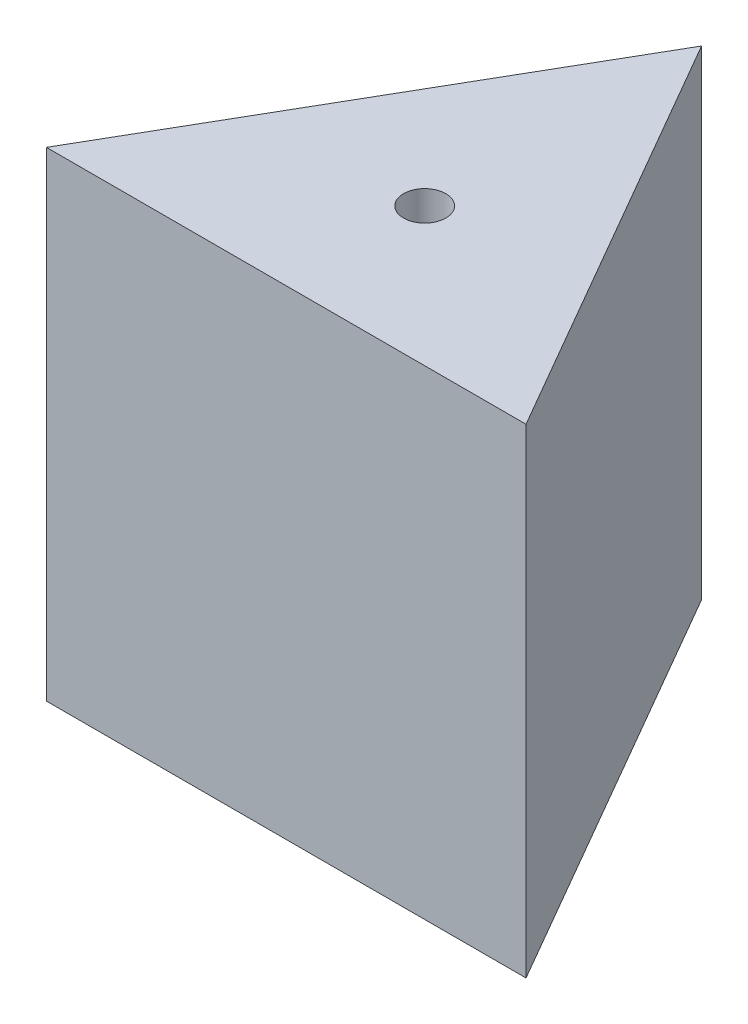
from build123d import *

# Parameters (mm, degrees)
BOSS_EXTRUDE1_DEPTH = 431.8
SKETCH2_R           = 19.05
CUT_EXTRUDE1_DEPTH  = 432.8


with BuildPart() as part:
    # Sketch1 → Boss-Extrude1 (new body)
    with BuildSketch(Plane(origin=(0, 0, 0), x_dir=(1, 0, 0), z_dir=(0, 1, 0))):
        Polygon((0, 0), (-215.9, -373.949769354), (215.9, -373.949769354), align=None)
    extrude(amount=BOSS_EXTRUDE1_DEPTH)

    # Sketch2 → Cut-Extrude1 (cut, through all)
    with BuildSketch(Plane(origin=(0, 431.8, 0), x_dir=(1, 0, 0), z_dir=(0, 1, 0))):
        with Locations((0, -249.299846236)):
            Circle(SKETCH2_R)
    extrude(amount=-CUT_EXTRUDE1_DEPTH, mode=Mode.SUBTRACT)


solid = part.part
